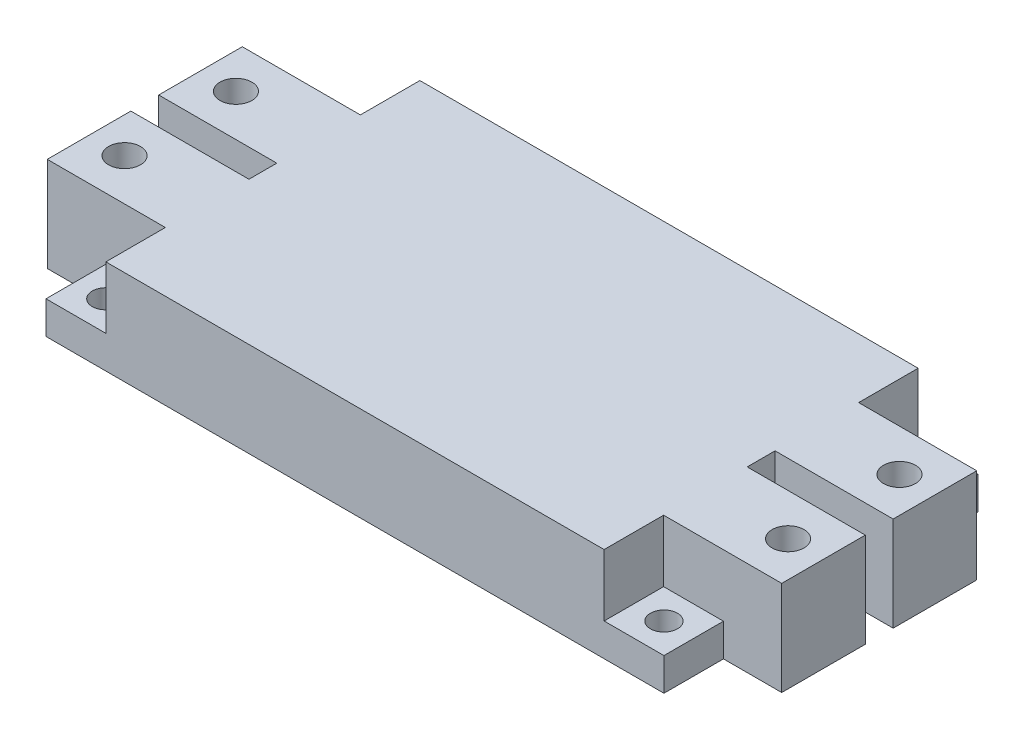
from build123d import *

# Parameters (mm, degrees)
SKETCH1_W           = 61
SKETCH1_H           = 62
SKETCH1_R           = 2.675
BASE_DEPTH          = 6.45
SKETCH2_W           = 49.185
SKETCH2_H           = 62
SEMICONDUCTOR_DEPTH = 12.22
SKETCH3_W           = 11.815
SKETCH3_H           = 16.5
SKETCH3_W_2         = 11.5
SKETCH3_R           = 3.15
TABS_DEPTH          = 18.67


with BuildPart() as part:
    # Sketch1 → Base (new body)
    with BuildSketch(Plane(origin=(0, 0, 0), x_dir=(1, 0, 0), z_dir=(0, 1, 0))):
        with Locations((-30.5, 0)):
            Rectangle(SKETCH1_W, SKETCH1_H)
        with Locations((-55.095, -25.095)):
            Circle(SKETCH1_R, mode=Mode.SUBTRACT)
        with Locations((-55.095, 25.09)):
            Circle(SKETCH1_R, mode=Mode.SUBTRACT)
    extrude(amount=BASE_DEPTH)

    # Sketch2 → Semiconductor (add)
    with BuildSketch(Plane(origin=(0, 6.45, 0), x_dir=(1, 0, 0), z_dir=(0, 1, 0))):
        with Locations((-24.5925, 0)):
            Rectangle(SKETCH2_W, SKETCH2_H)
    extrude(amount=SEMICONDUCTOR_DEPTH)

    # Sketch3 → Tabs (add)
    with BuildSketch(Plane.XZ):
        with Locations((-55.0925, 11)):
            Rectangle(SKETCH3_W, SKETCH3_H)
        with Locations((-55.0925, -11)):
            Rectangle(SKETCH3_W, SKETCH3_H)
        with Locations((-66.75, -11)):
            Rectangle(SKETCH3_W_2, SKETCH3_H)
        with Locations((-65.5, -11)):
            Circle(SKETCH3_R, mode=Mode.SUBTRACT)
        with Locations((-66.75, 11)):
            Rectangle(SKETCH3_W_2, SKETCH3_H)
        with Locations((-65.5, 11)):
            Circle(SKETCH3_R, mode=Mode.SUBTRACT)
    extrude(amount=-TABS_DEPTH)

    # Mirror 2: part across plane


with BuildPart() as part_1:
    add(part.part)
    add(part.part.mirror(Plane(origin=(0, 6.45, 0), x_dir=(0, 0, 1), z_dir=(1, 0, 0))))


solid = part_1.part
